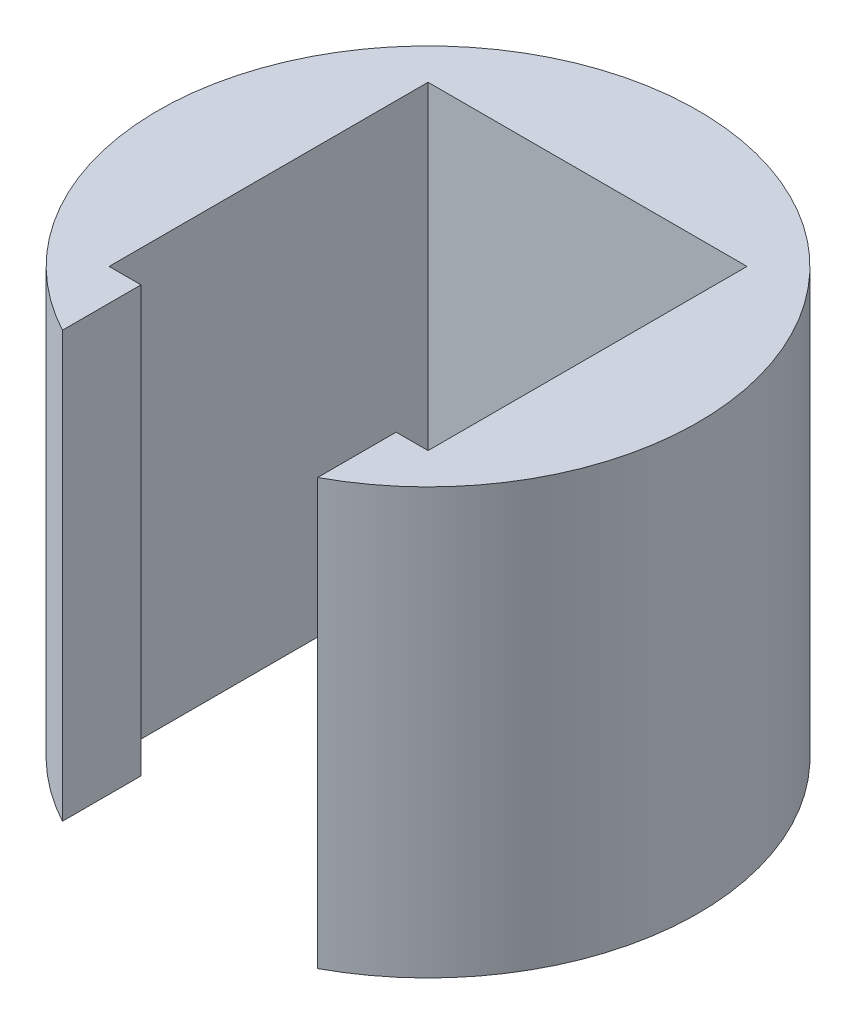
from build123d import *

# Parameters (mm, degrees)
BOSS_EXTRUDE2_DEPTH = 20


with BuildPart() as part:
    # Sketch1 → Boss-Extrude2 (new body)
    with BuildSketch(Plane(origin=(0, 0, 0), x_dir=(1, 0, 0), z_dir=(0, 1, 0))):
        with BuildLine():
            Line((5.999643171, -7.5), (7.5, -7.5))
            Line((7.5, -7.5), (7.5, 7.5))
            Line((7.5, 7.5), (-7.5, 7.5))
            Line((-7.5, 7.5), (-7.5, -7.5))
            Line((-7.5, -7.5), (-5.999643171, -7.5))
            Line((-5.999643171, -7.5), (-5.999643171, -11.193492834))
            ThreePointArc((-5.999643171, -11.193492834), (0, 12.7), (5.999643171, -11.193492834))
            Line((5.999643171, -11.193492834), (5.999643171, -7.5))
        make_face()
    extrude(amount=BOSS_EXTRUDE2_DEPTH)


solid = part.part
